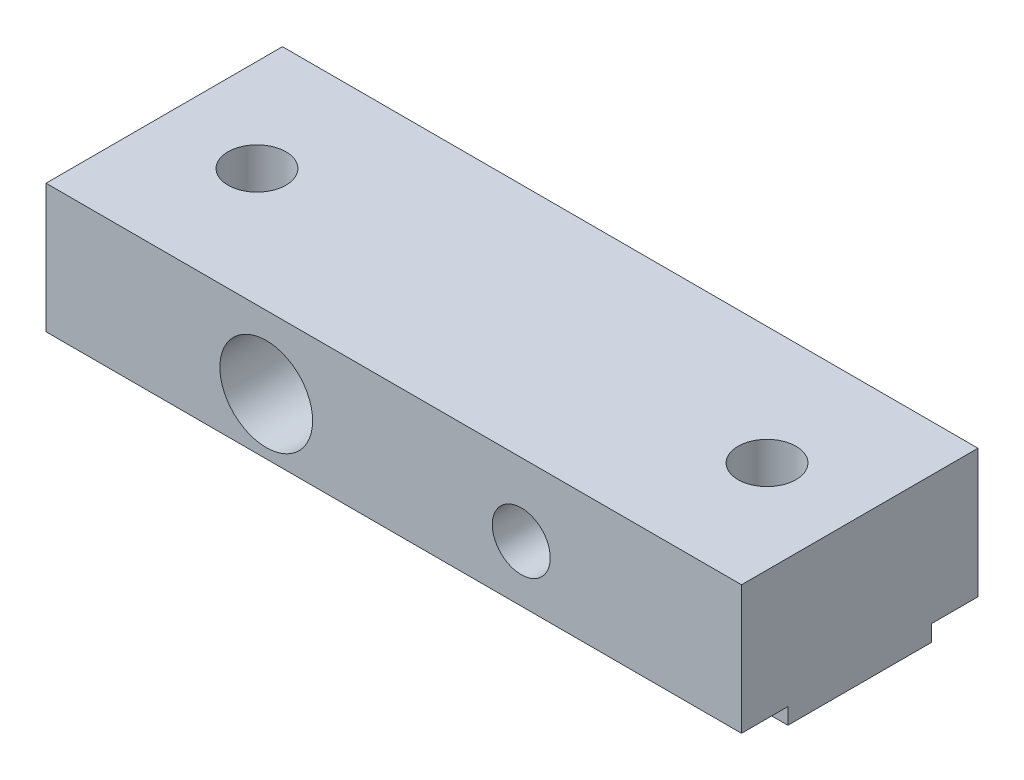
from build123d import *

# Parameters (mm, degrees)
SKETCH1_W                  = 30
SKETCH1_H                  = 10.2
BOSS_EXTRUDE1_DEPTH        = 6.25
F_4_0_4_DIAMETER_HOLE1_D   = 4
F_2_5_2_5_DIAMETER_HOLE2_D = 2.5
F_2_5_2_5_DIAMETER_HOLE1_D = 2.5
SKETCH6_W                  = 2
SKETCH6_H                  = 0.7
CUT_EXTRUDE1_DEPTH         = 31


with BuildPart() as part:
    # Sketch1 → Boss-Extrude1 (new body)
    with BuildSketch(Plane(origin=(0, 0, 0), x_dir=(1, 0, 0), z_dir=(0, 1, 0))):
        with Locations((15, 5.1)):
            Rectangle(SKETCH1_W, SKETCH1_H)
    extrude(amount=BOSS_EXTRUDE1_DEPTH)

    # Ø4.0 (4) Diameter Hole1 (through all)
    with Locations(Plane.XY):
        with Locations((9.5, 3.125)):
            Hole(F_4_0_4_DIAMETER_HOLE1_D / 2)

    # Ø2.5 (2.5) Diameter Hole2 (through all)
    with Locations(Plane.XY):
        with Locations((20.5, 3.125)):
            Hole(F_2_5_2_5_DIAMETER_HOLE2_D / 2)

    # Ø2.5 (2.5) Diameter Hole1 (through all)
    with Locations(Plane(origin=(0, 6.25, 0), x_dir=(-1, 0, 0), z_dir=(0, 1, 0))):
        with Locations((-4, -5.1), (-26, -5.1)):
            Hole(F_2_5_2_5_DIAMETER_HOLE1_D / 2)

    # Sketch6 → Cut-Extrude1 (cut, through all)
    with BuildSketch(Plane(origin=(30, 0, 0), x_dir=(0, 0, -1), z_dir=(1, 0, 0))):
        with Locations((9.2, 0.35)):
            Rectangle(SKETCH6_W, SKETCH6_H)
    cut_extrude1 = extrude(amount=-CUT_EXTRUDE1_DEPTH, mode=Mode.SUBTRACT)

    # Mirror1: Cut-Extrude1 across plane
    add(cut_extrude1.mirror(Plane.XY.offset(-5.1)), mode=Mode.SUBTRACT)


solid = part.part
